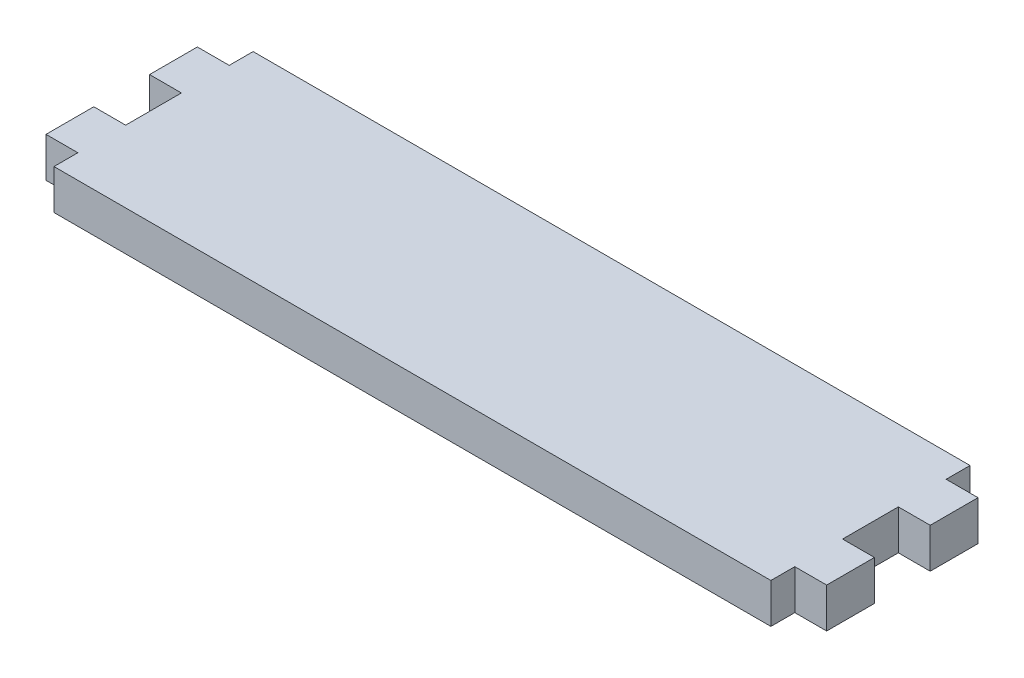
from build123d import *

# Parameters (mm, degrees)
BOSS_EXTRUDE1_DEPTH = 5


with BuildPart() as part:
    # Sketch1 → Boss-Extrude1 (new body)
    with BuildSketch(Plane(origin=(0, 0, 0), x_dir=(1, 0, 0), z_dir=(0, 1, 0))):
        Polygon((0, 0), (0, 3), (-4, 3), (-4, 9), (0, 9), (0, 16), (-4, 16), (-4, 22), (0, 22), (0, 25), (90, 25), (90, 22), (94, 22), (94, 16), (90, 16), (90, 9), (94, 9), (94, 3), (90, 3), (90, 0), align=None)
    extrude(amount=BOSS_EXTRUDE1_DEPTH)


solid = part.part
